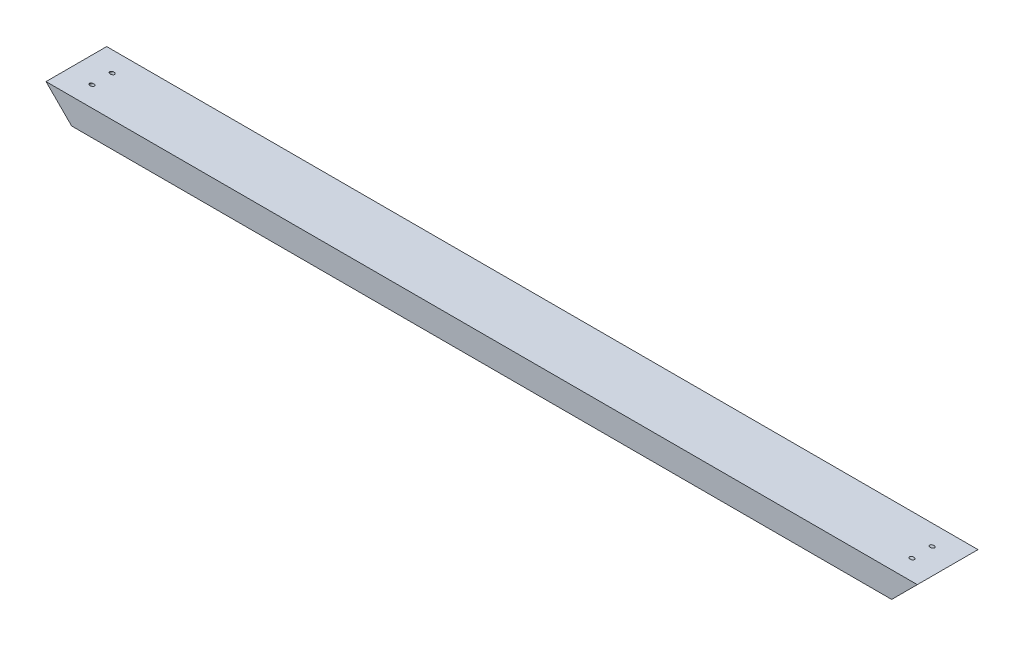
from build123d import *

# Parameters (mm, degrees)
BOSS_EXTRUDE1_DEPTH = 88.9
SKETCH2_R           = 2.5796875
CUT_EXTRUDE1_DEPTH  = 903.74963352
SKETCH3_R           = 2.5796875
CUT_EXTRUDE2_DEPTH  = 903.74963352


with BuildPart() as part:
    # Sketch1 → Boss-Extrude1 (new body)
    with BuildSketch(Plane.XY):
        Polygon((-29.256301488, 26.487163625), (1247.424473663, 26.487163625), (1209.831898512, -11.105411527), (8.336273663, -11.105411527), align=None)
    extrude(amount=BOSS_EXTRUDE1_DEPTH)

    # Sketch2 → Cut-Extrude1 (cut, through all)
    with BuildSketch(Plane(origin=(-1.384568932, -1.384568932, 0), x_dir=(0, 0, 1), z_dir=(-0.707106781, -0.707106781, 0))):
        with Locations((29.633333333, 12.834617376)):
            Circle(SKETCH2_R)
        with Locations((59.266666667, 12.834617376)):
            Circle(SKETCH2_R)
    extrude(amount=-CUT_EXTRUDE1_DEPTH, mode=Mode.SUBTRACT)

    # Sketch3 → Cut-Extrude2 (cut, through all)
    with BuildSketch(Plane(origin=(610.468655019, -610.468655019, 0), x_dir=(0, 0, -1), z_dir=(0.707106781, -0.707106781, 0))):
        with Locations((-59.266666667, 874.209592547)):
            Circle(SKETCH3_R)
        with Locations((-29.633333333, 874.209592547)):
            Circle(SKETCH3_R)
    extrude(amount=-CUT_EXTRUDE2_DEPTH, mode=Mode.SUBTRACT)


solid = part.part
